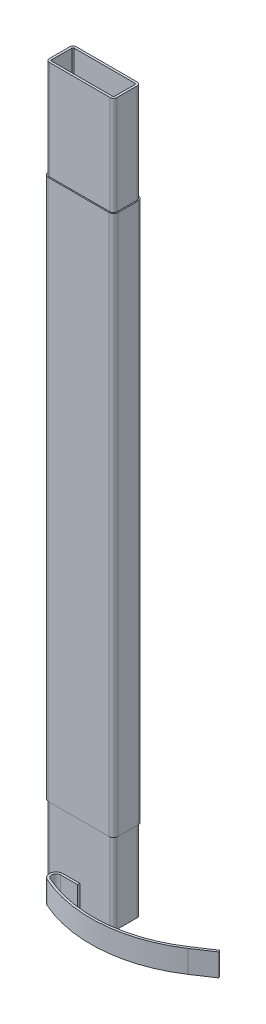
from build123d import *

# Parameters (mm, degrees)
EXTRUDE_THIN1_DEPTH      = 30.4
EXTRUDE_THIN1_DEPTH_BACK = 1.6
EXTRUDE_THIN2_DEPTH      = 12
EXTRUDE_THIN3_DEPTH      = 1


with BuildPart() as part:
    # Sketch1 → Extrude-Thin1 (new body, two sides)
    with BuildSketch(Plane(origin=(0, 0, 0), x_dir=(1, 0, 0), z_dir=(0, 1, 0))) as extrude_thin1_sk:
        with BuildLine():
            Line((1.35, -0.6), (-1.35, -0.6))
            ThreePointArc((-1.35, -0.6), (-1.456066017, -0.556066017), (-1.5, -0.45))
            Line((-1.5, -0.45), (-1.5, 0.45))
            ThreePointArc((-1.5, 0.45), (-1.456066017, 0.556066017), (-1.35, 0.6))
            Line((-1.35, 0.6), (1.35, 0.6))
            ThreePointArc((1.35, 0.6), (1.456066017, 0.556066017), (1.5, 0.45))
            Line((1.5, 0.45), (1.5, -0.45))
            ThreePointArc((1.5, -0.45), (1.456066017, -0.556066017), (1.35, -0.6))
        make_face()
        with BuildLine():
            Line((1.35, -0.5), (-1.35, -0.5))
            ThreePointArc((-1.35, -0.5), (-1.385355339, -0.485355339), (-1.4, -0.45))
            Line((-1.4, -0.45), (-1.4, 0.45))
            ThreePointArc((-1.4, 0.45), (-1.385355339, 0.485355339), (-1.35, 0.5))
            Line((-1.35, 0.5), (1.35, 0.5))
            ThreePointArc((1.35, 0.5), (1.385355339, 0.485355339), (1.4, 0.45))
            Line((1.4, 0.45), (1.4, -0.45))
            ThreePointArc((1.4, -0.45), (1.385355339, -0.485355339), (1.35, -0.5))
        make_face(mode=Mode.SUBTRACT)
    extrude(amount=EXTRUDE_THIN1_DEPTH)
    extrude(extrude_thin1_sk.sketch, amount=-EXTRUDE_THIN1_DEPTH_BACK)

    # Sketch2 → Extrude-Thin2 (add, symmetric)
    with BuildSketch(Plane(origin=(0, 14, 0), x_dir=(-1, 0, 0), z_dir=(0, 1, 0))):
        with BuildLine():
            Line((-1.55, -0.45), (-1.55, 0.45))
            ThreePointArc((-1.55, 0.45), (-1.491421356, 0.591421356), (-1.35, 0.65))
            Line((-1.35, 0.65), (1.35, 0.65))
            ThreePointArc((1.35, 0.65), (1.491421356, 0.591421356), (1.55, 0.45))
            Line((1.55, 0.45), (1.55, -0.45))
            ThreePointArc((1.55, -0.45), (1.491421356, -0.591421356), (1.35, -0.65))
            Line((1.35, -0.65), (-1.35, -0.65))
            ThreePointArc((-1.35, -0.65), (-1.491421356, -0.591421356), (-1.55, -0.45))
        make_face()
        with BuildLine():
            Line((-1.5, -0.45), (-1.5, 0.45))
            ThreePointArc((-1.5, 0.45), (-1.456066017, 0.556066017), (-1.35, 0.6))
            Line((-1.35, 0.6), (1.35, 0.6))
            ThreePointArc((1.35, 0.6), (1.456066017, 0.556066017), (1.5, 0.45))
            Line((1.5, 0.45), (1.5, -0.45))
            ThreePointArc((1.5, -0.45), (1.456066017, -0.556066017), (1.35, -0.6))
            Line((1.35, -0.6), (-1.35, -0.6))
            ThreePointArc((-1.35, -0.6), (-1.456066017, -0.556066017), (-1.5, -0.45))
        make_face(mode=Mode.SUBTRACT)
    extrude(amount=EXTRUDE_THIN2_DEPTH, both=True)

    # Sketch3 → Extrude-Thin3 (add)
    with BuildSketch(Plane.XZ.offset(0.5)):
        with BuildLine():
            Line((0, 0.6), (-0.75, 0.6))
            ThreePointArc((-0.75, 0.6), (-1.043338791, 0.837132251), (-0.872943663, 1.173650974))
            ThreePointArc((-0.872943663, 1.173650974), (2.074168878, 1.680733699), (4.9, 0.702324945))
            Line((4.9, 0.702324945), (5.733615576, 0.149979879))
            Line((5.733615576, 0.149979879), (5.678381069, 0.066618321))
            Line((5.678381069, 0.066618321), (4.844765493, 0.618963387))
            ThreePointArc((4.844765493, 0.618963387), (2.066031557, 1.581065329), (-0.831962442, 1.082433983))
            ThreePointArc((-0.831962442, 1.082433983), (-0.945559194, 0.858088167), (-0.75, 0.7))
            Line((-0.75, 0.7), (0, 0.7))
            Line((0, 0.7), (0, 0.6))
        make_face()
    extrude(amount=EXTRUDE_THIN3_DEPTH)


solid = part.part
